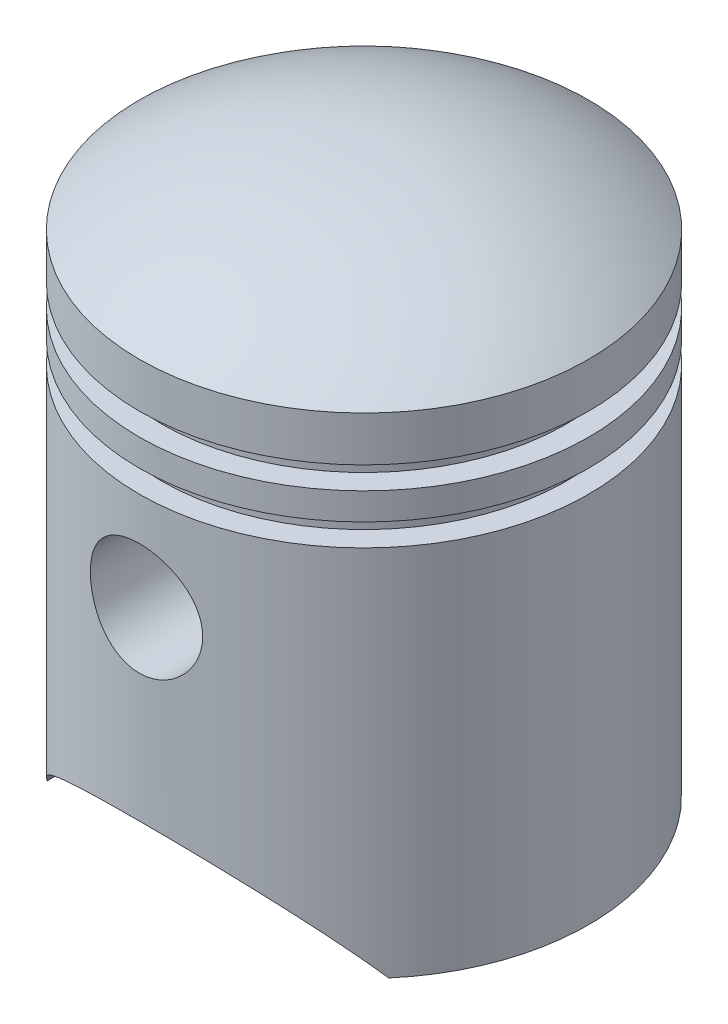
from build123d import *

# Parameters (mm, degrees)
SKETCH3_R               = 6.25
CUT_EXTRUDE1_DEPTH      = 26.0000001
CUT_EXTRUDE1_DEPTH_BACK = 26.0000001
BOSS_EXTRUDE1_START     = 12
SKETCH4_R               = 7.25
SKETCH4_R_2             = 6.25
BOSS_EXTRUDE1_DEPTH     = 11.925666


with BuildPart() as part:
    # Sketch2 → Revolve1 (revolve)
    with BuildSketch(Plane.XY):
        with BuildLine():
            Line((25, 0), (25, 41.5))
            Line((25, 41.5), (22.5, 41.5))
            Line((22.5, 41.5), (22.5, 44))
            Line((22.5, 44), (25, 44))
            Line((25, 44), (25, 47))
            Line((25, 47), (22.5, 47))
            Line((22.5, 47), (22.5, 49.5))
            Line((22.5, 49.5), (25, 49.5))
            Line((25, 49.5), (25, 54.5))
            ThreePointArc((25, 54.5), (13.174901691, 60.609067785), (0, 62.5))
            Line((0, 62.5), (0, 60.49936285))
            ThreePointArc((0, 60.49936285), (12.069492637, 58.859165445), (23, 53.484511145))
            Line((23, 53.484511145), (23, 51.5))
            Line((23, 51.5), (20.5, 51.5))
            Line((20.5, 51.5), (20.5, 45.5))
            Line((20.5, 45.5), (20.5, 39.5))
            Line((20.5, 39.5), (23, 39.5))
            Line((23, 39.5), (23, 0))
            Line((23, 0), (25, 0))
        make_face()
    revolve(axis=Axis((0, 62.5, 0), (0, -1, 0)))

    # Sketch3 → Cut-Extrude1 (cut, two sides)
    with BuildSketch(Plane.XY) as cut_extrude1_sk:
        with Locations((0, 30.5)):
            Circle(SKETCH3_R)
        with BuildLine():
            Line((-19, 0), (19, 0))
            ThreePointArc((19, 0), (0, 10), (-19, 0))
        make_face()
    extrude(amount=CUT_EXTRUDE1_DEPTH, mode=Mode.SUBTRACT)
    extrude(cut_extrude1_sk.sketch, amount=-CUT_EXTRUDE1_DEPTH_BACK, mode=Mode.SUBTRACT)

    # Sketch4 → Boss-Extrude1 (add)
    with BuildSketch(Plane.XY.offset(BOSS_EXTRUDE1_START)):
        with Locations((0, 30.5)):
            Circle(SKETCH4_R)
        with Locations((0, 30.5)):
            Circle(SKETCH4_R_2, mode=Mode.SUBTRACT)
    boss_extrude1 = extrude(amount=BOSS_EXTRUDE1_DEPTH)

    # Mirror1: Boss-Extrude1 across plane
    add(boss_extrude1.mirror(Plane.XY))


solid = part.part
